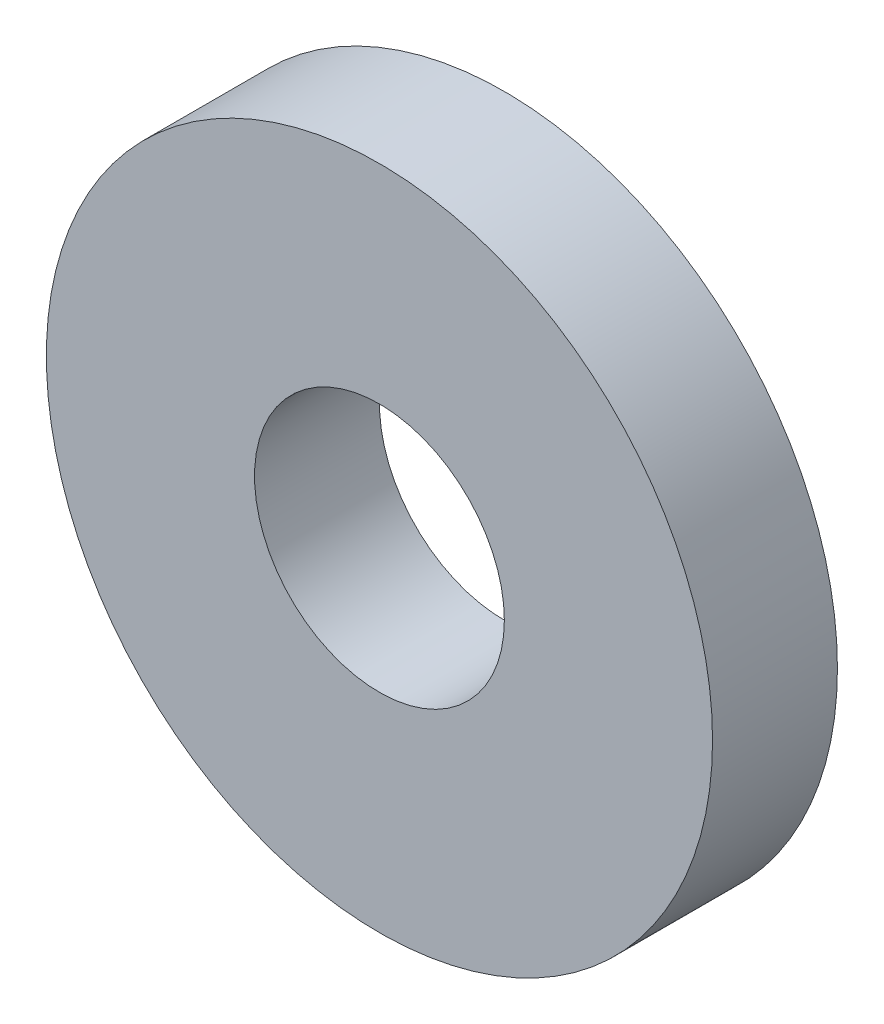
from build123d import *

# Parameters (mm, degrees)
SKETCH1_R           = 40
SKETCH1_R_2         = 15
BOSS_EXTRUDE1_DEPTH = 15


with BuildPart() as part:
    # Sketch1 → Boss-Extrude1 (new body)
    with BuildSketch(Plane.XY):
        Circle(SKETCH1_R)
        Circle(SKETCH1_R_2, mode=Mode.SUBTRACT)
    extrude(amount=BOSS_EXTRUDE1_DEPTH)


solid = part.part
